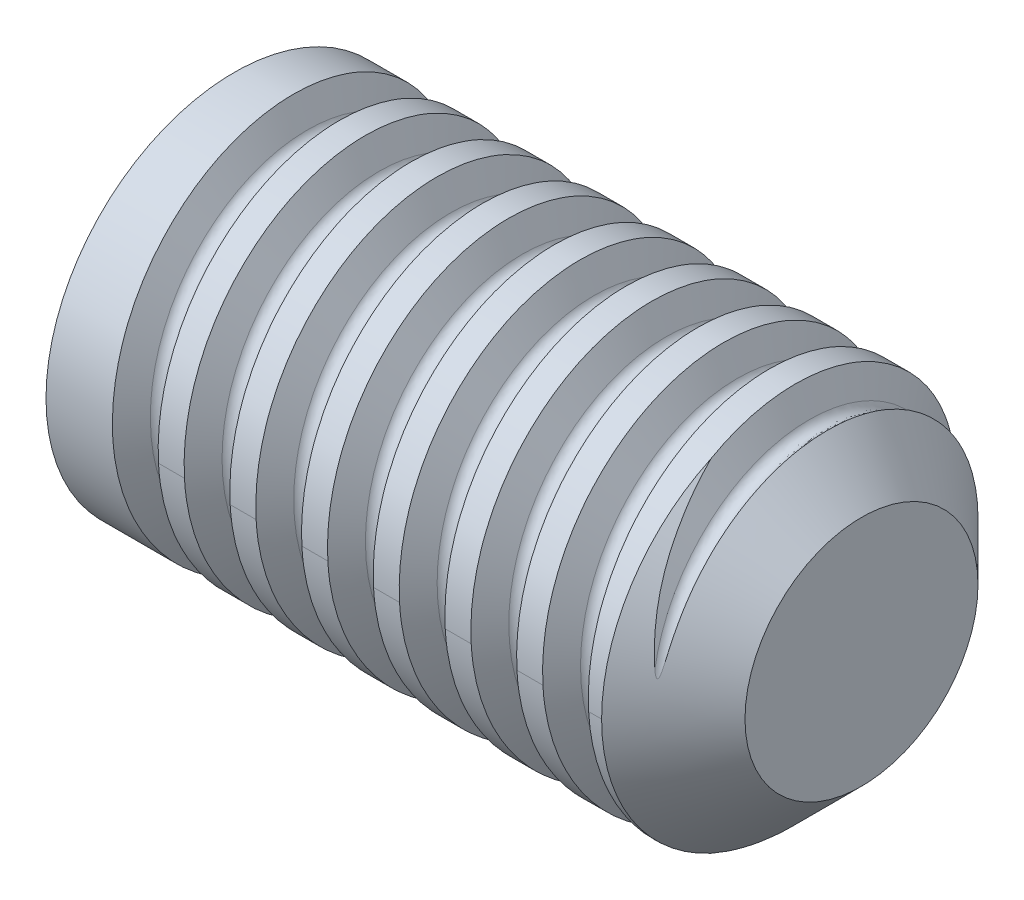
from build123d import *

# Parameters (mm, degrees)
SKETCH1_W          = 7
SKETCH1_H          = 2.1
CHAMFER1_SIZE      = 0.8
CUT_EXTRUDE1_DEPTH = 7.5
CUT_SWEEP1_PITCH   = 0.8
CUT_SWEEP1_HEIGHT  = 6.5
CUT_SWEEP1_RADIUS  = 2.1


with BuildPart() as part:
    # Sketch1 → Revolve1 (revolve)
    with BuildSketch(Plane.XY):
        with Locations((7.5, 1.05)):
            Rectangle(SKETCH1_W, SKETCH1_H)
    revolve(axis=Axis((-90.706569874, 0, 0), (1, 0, 0)))

    # Chamfer1
    chamfer1_edges = [part.edges().sort_by_distance(p)[0] for p in [
        (11, -2.1, 0),
    ]]
    chamfer(chamfer1_edges, length=CHAMFER1_SIZE)

    # Sketch3 → Cut-Extrude1 (cut)
    with BuildSketch(Plane(origin=(0, 0, 0), x_dir=(0, 0, -1), z_dir=(1, 0, 0))):
        Polygon((-1.732050808, 0), (-0.866025404, -1.5), (0.866025404, -1.5), (1.732050808, 0), (0.866025404, 1.5), (-0.866025404, 1.5), align=None)
    extrude(amount=CUT_EXTRUDE1_DEPTH, mode=Mode.SUBTRACT)

    # Cut-Sweep1: sweep along a helix
    with BuildLine() as cut_sweep1_path:
        Helix(CUT_SWEEP1_PITCH, CUT_SWEEP1_HEIGHT, CUT_SWEEP1_RADIUS, center=(11, 0, 0), direction=(-1, 0, 0))
    # Sketch8 → Cut-Sweep1 (sweep, cut)
    with BuildSketch(Plane(origin=(0, 0, 0), x_dir=(1, 0, 0), z_dir=(0, 1, 0))):
        with BuildLine():
            Line((11.100025934, 1.831396255), (11.525136154, 2.567708755))
            Line((11.525136154, 2.567708755), (10.474863846, 2.567708755))
            Line((10.474863846, 2.567708755), (10.899974066, 1.831396255))
            ThreePointArc((10.899974066, 1.831396255), (11, 1.773646255), (11.100025934, 1.831396255))
        make_face()
    sweep(path=cut_sweep1_path.line, is_frenet=True, mode=Mode.SUBTRACT)


solid = part.part
